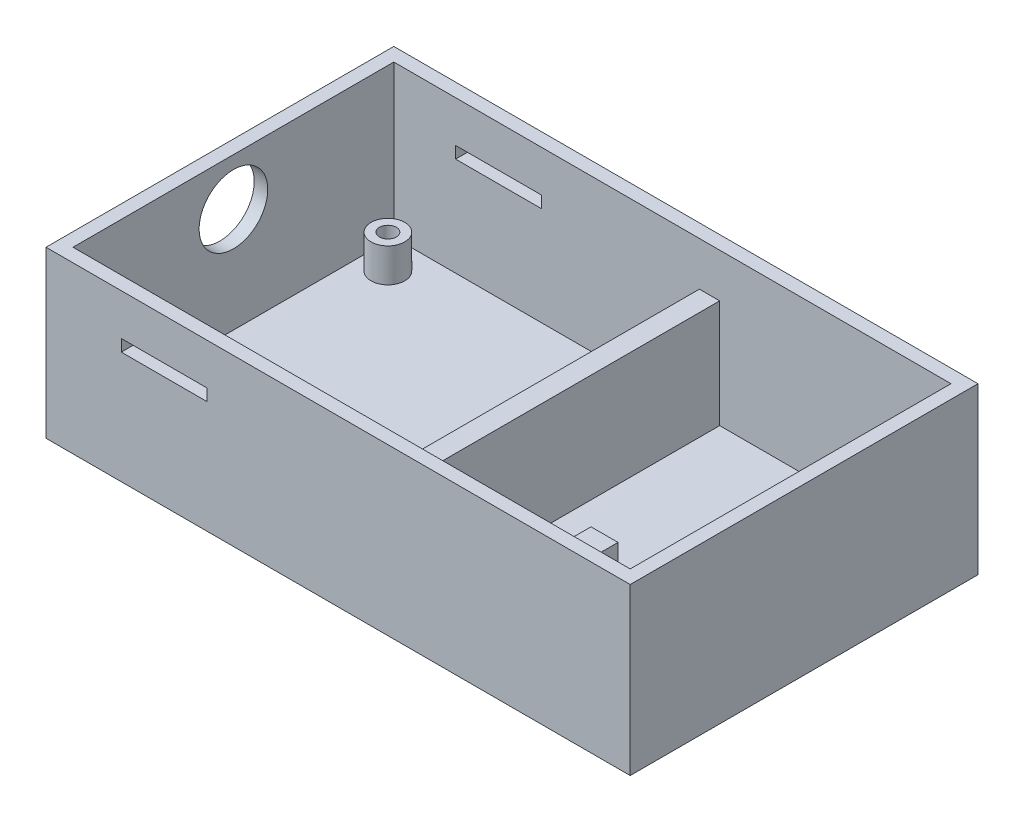
from build123d import *

# Parameters (mm, degrees)
SKETCH1_W             = 173
SKETCH1_H             = 103
SKETCH1_W_2           = 165
SKETCH1_H_2           = 95
BOSS_EXTRUDE1_DEPTH   = 45
SKETCH1_3_W           = 173
SKETCH1_3_H           = 103
BOSS_EXTRUDE2_DEPTH   = 4
SKETCH5_W             = 6
SKETCH5_H             = 95
BOSS_EXTRUDE3_DEPTH   = 32
SKETCH6_R             = 5
SKETCH6_R_2           = 2.5
STANDOFFINSERTS_DEPTH = 10
SKETCH7_W             = 25.4
SKETCH7_H             = 3.5
CUT_EXTRUDE1_DEPTH    = 142.831766541
SKETCH8_W             = 8
SKETCH8_H             = 25
BOSS_EXTRUDE5_DEPTH   = 25
SKETCH9_R             = 10.16
CUT_EXTRUDE2_DEPTH    = 10


with BuildPart() as part:
    # Sketch1 → Boss-Extrude1 (new body)
    with BuildSketch(Plane(origin=(0, 0, 0), x_dir=(1, 0, 0), z_dir=(0, 1, 0))):
        Rectangle(SKETCH1_W, SKETCH1_H)
        Rectangle(SKETCH1_W_2, SKETCH1_H_2, mode=Mode.SUBTRACT)
    extrude(amount=BOSS_EXTRUDE1_DEPTH)

    # Sketch1_3 → Boss-Extrude2 (add)
    with BuildSketch(Plane(origin=(0, 0, 0), x_dir=(1, 0, 0), z_dir=(0, 1, 0))):
        Rectangle(SKETCH1_3_W, SKETCH1_3_H)
    extrude(amount=-BOSS_EXTRUDE2_DEPTH)

    # Sketch5 → Boss-Extrude3 (add)
    with BuildSketch(Plane(origin=(0, 0, 0), x_dir=(1, 0, 0), z_dir=(0, 1, 0))):
        with Locations((11, 0)):
            Rectangle(SKETCH5_W, SKETCH5_H)
    extrude(amount=BOSS_EXTRUDE3_DEPTH)

    # Sketch6 → StandoffInserts (add)
    # profile 1 of 4: a face of its own
    with BuildSketch(Plane(origin=(0, 0, 0), x_dir=(1, 0, 0), z_dir=(0, 1, 0))):
        with Locations((-74.75, -38)):
            Circle(SKETCH6_R)
        with Locations((-74.75, -38)):
            Circle(SKETCH6_R_2, mode=Mode.SUBTRACT)
    # profile 2 of 4: a face of its own
    with BuildSketch(Plane(origin=(0, 0, 0), x_dir=(1, 0, 0), z_dir=(0, 1, 0))):
        with Locations((0.25, -38)):
            Circle(SKETCH6_R)
        with Locations((0.25, -38)):
            Circle(SKETCH6_R_2, mode=Mode.SUBTRACT)
    # profile 3 of 4: a face of its own
    with BuildSketch(Plane(origin=(0, 0, 0), x_dir=(1, 0, 0), z_dir=(0, 1, 0))):
        with Locations((-74.75, 38)):
            Circle(SKETCH6_R)
        with Locations((-74.75, 38)):
            Circle(SKETCH6_R_2, mode=Mode.SUBTRACT)
    # profile 4 of 4: a face of its own
    with BuildSketch(Plane(origin=(0, 0, 0), x_dir=(1, 0, 0), z_dir=(0, 1, 0))):
        with Locations((0.25, 38)):
            Circle(SKETCH6_R)
        with Locations((0.25, 38)):
            Circle(SKETCH6_R_2, mode=Mode.SUBTRACT)
    extrude(amount=STANDOFFINSERTS_DEPTH)

    # Sketch7 → Cut-Extrude1 (cut, through all)
    with BuildSketch(Plane(origin=(0, 0, -51.5), x_dir=(-1, 0, 0), z_dir=(0, 0, -1))):
        with Locations((51.5, 31)):
            Rectangle(SKETCH7_W, SKETCH7_H)
    extrude(amount=-CUT_EXTRUDE1_DEPTH, mode=Mode.SUBTRACT)

    # Sketch8 → Boss-Extrude5 (add)
    with BuildSketch(Plane(origin=(0, 0, 0), x_dir=(1, 0, 0), z_dir=(0, 1, 0))):
        with Locations((49.90120524, -35)):
            Rectangle(SKETCH8_W, SKETCH8_H)
    extrude(amount=BOSS_EXTRUDE5_DEPTH)

    # Sketch9 → Cut-Extrude2 (cut)
    with BuildSketch(Plane.ZY.offset(86.5)):
        with Locations((0, 31)):
            Circle(SKETCH9_R)
    extrude(amount=-CUT_EXTRUDE2_DEPTH, mode=Mode.SUBTRACT)


solid = part.part
